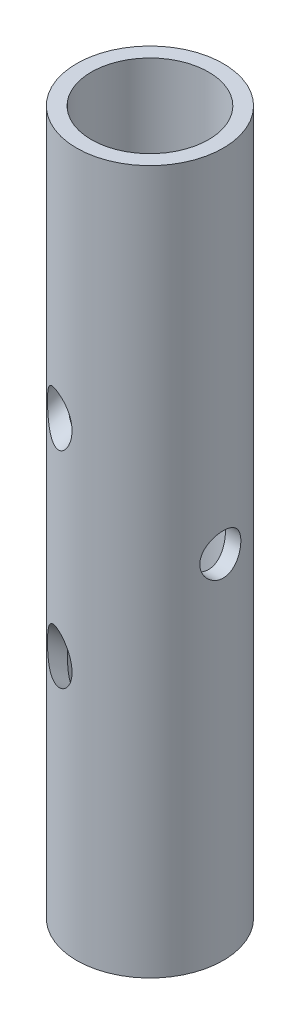
from build123d import *

# Parameters (mm, degrees)
SKETCH_1_R          = 12.5
SKETCH_1_R_2        = 10
EXTRUDE_1_DEPTH     = 120
SKETCH_2_R          = 3.5
CUT_EXTRUDE_1_DEPTH = 12.5
SWEEP_3_PROFILE_R   = 3.5


with BuildPart() as part:
    # 草图1 → 凸台-拉伸1 (new body)
    with BuildSketch(Plane(origin=(0, 0, 0), x_dir=(1, 0, 0), z_dir=(0, 1, 0))):
        Circle(SKETCH_1_R)
        Circle(SKETCH_1_R_2, mode=Mode.SUBTRACT)
    extrude(amount=EXTRUDE_1_DEPTH)

    # 草图2 → 切除-拉伸1 (cut, symmetric)
    with BuildSketch(Plane(origin=(0, 0, 0), x_dir=(0, 0, -1), z_dir=(1, 0, 0))):
        with Locations((0, 60)):
            Circle(SKETCH_2_R)
    extrude(amount=CUT_EXTRUDE_1_DEPTH, both=True, mode=Mode.SUBTRACT)

    # 切除-扫描3: sweep along a path in 草图10
    with BuildLine(Plane(origin=(0, 0, 0), x_dir=(0.342020143, 0, -0.939692621), z_dir=(0.939692621, 0, 0.342020143))) as sweep_3_path:
        Line((42.494333557, 116.01263537), (-37.5, 60))
        Line((-37.5, 60), (79.181849156, -21.701510351))
    # 切除-扫描3 profile (on start of the path) → 切除-扫描3 (sweep, cut)
    with BuildSketch(Plane(origin=(14.533918054, 116.01263537, -39.931611668), x_dir=(0, 0.801864671, 0.59750569), z_dir=(-0.2801665, -0.573576436, 0.769751131))):
        Circle(SWEEP_3_PROFILE_R)
    sweep(path=sweep_3_path.line, transition=Transition.RIGHT, mode=Mode.SUBTRACT)


solid = part.part
